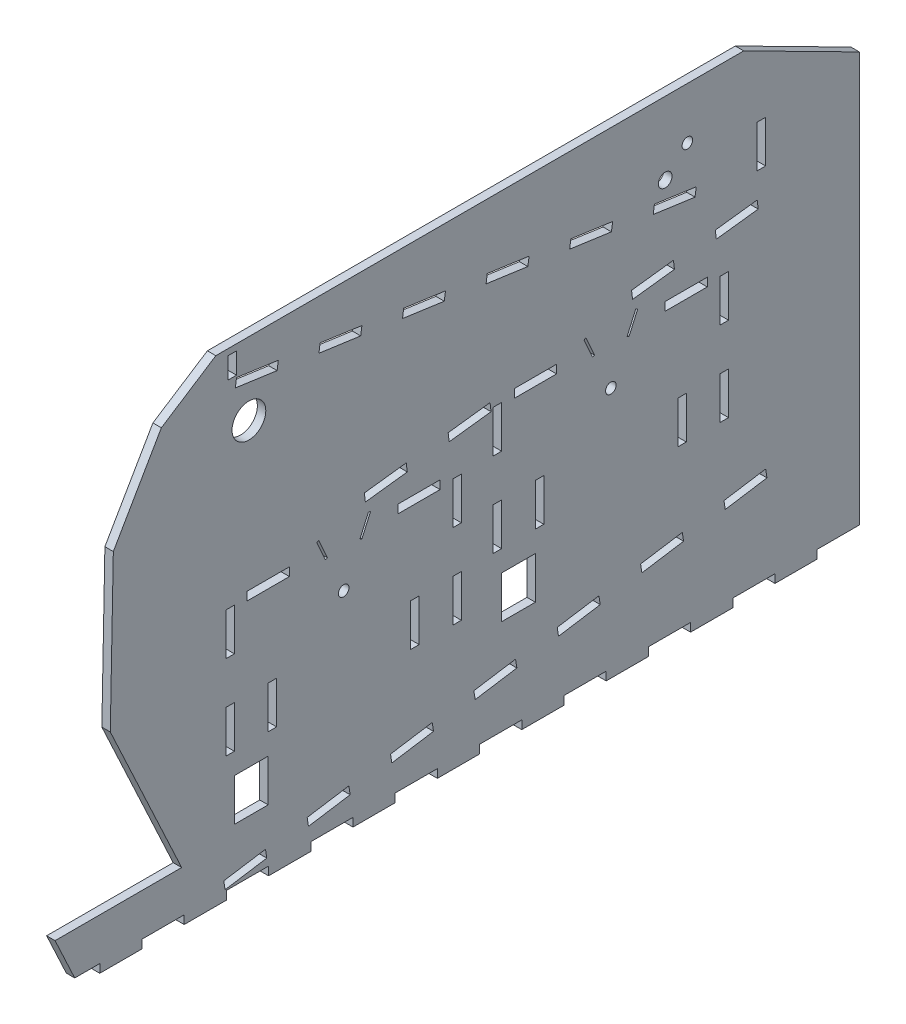
from build123d import *

# Parameters (mm, degrees)
SKETCH_1_W          = 16
SKETCH_1_H          = 20
SKETCH_1_W_2        = 4
SKETCH_1_R          = 2.5
SKETCH_1_W_3        = 20
SKETCH_1_H_2        = 4
SKETCH_1_H_3        = 10
SKETCH_1_R_2        = 3.25
EXTRUDE_12_DEPTH    = 4
SKETCH_4_R          = 8
CUT_EXTRUDE_4_DEPTH = 4


with BuildPart() as part:
    # Эскиз1 → Бобышка-Вытянуть12 (new body)
    with BuildSketch(Plane(origin=(0, 0, 0), x_dir=(0, 0, -1), z_dir=(1, 0, 0))):
        Polygon((-110.600725883, -2.680262939), (-76.770509831, -75.229395384), (-136.770509831, -75.229395384), (-127.444356668, -95.229395384), (-115.579126036, -95.229395384), (-115.579126036, -99.229395384), (-95.579126036, -99.229395384), (-95.579126036, -95.229395384), (-75.579126036, -95.229395384), (-75.579126036, -99.229395384), (-55.579126036, -99.229395384), (-55.579126036, -95.229395384), (-35.579126036, -95.229395384), (-35.579126036, -99.229395384), (-15.579126036, -99.229395384), (-15.579126036, -95.229395384), (4.420873964, -95.229395384), (4.420873964, -99.229395384), (24.420873964, -99.229395384), (24.420873964, -95.229395384), (44.420873964, -95.229395384), (44.420873964, -99.229395384), (64.420873964, -99.229395384), (64.420873964, -95.229395384), (84.420873964, -95.229395384), (84.420873964, -99.229395384), (104.420873964, -99.229395384), (104.420873964, -95.229395384), (124.420873964, -95.229395384), (124.420873964, -99.229395384), (144.420873964, -99.229395384), (144.420873964, -95.229395384), (164.420873964, -95.229395384), (164.420873964, -99.229395384), (184.420873964, -99.229395384), (184.420873964, -95.229395384), (204.420873964, -95.229395384), (204.420873964, -99.229395384), (224.420873964, -99.229395384), (224.420873964, -95.229395384), (244.420873964, -95.229395384), (244.420873964, 98.944706715), (189.622245063, 126.770604616), (-34.770509831, 126.770604616), (-60.579126036, 126.770604616), (-86.407669291, 110.078554792), (-109.160554377, 70.669401803), align=None)
        Polygon((-56.80504604, -90.676966538), (-37.046421413, -87.57910391), (-36.426848887, -91.530828835), (-56.185473514, -94.628691463), align=None, mode=Mode.SUBTRACT)
        with Locations((-43.770509831, -60)):
            Rectangle(SKETCH_1_W, SKETCH_1_H, mode=Mode.SUBTRACT)
        Polygon((-17.297512418, -84.419587937), (2.461112209, -81.321725309), (3.080684734, -85.273450234), (-16.677939892, -88.371312862), align=None, mode=Mode.SUBTRACT)
        Polygon((22.210021204, -78.162209336), (41.968645831, -75.064346707), (42.588218356, -79.016071633), (22.829593729, -82.113934261), align=None, mode=Mode.SUBTRACT)
        with Locations((-53.770509831, -30)):
            Rectangle(SKETCH_1_W_2, SKETCH_1_H, mode=Mode.SUBTRACT)
        with Locations((-53.770509831, 10)):
            Rectangle(SKETCH_1_W_2, SKETCH_1_H, mode=Mode.SUBTRACT)
        with Locations((-33.770509831, -30)):
            Rectangle(SKETCH_1_W_2, SKETCH_1_H, mode=Mode.SUBTRACT)
        with Locations((33.770509831, -30)):
            Rectangle(SKETCH_1_W_2, SKETCH_1_H, mode=Mode.SUBTRACT)
        with Locations((53.770509831, -30)):
            Rectangle(SKETCH_1_W_2, SKETCH_1_H, mode=Mode.SUBTRACT)
        Circle(SKETCH_1_R, mode=Mode.SUBTRACT)
        with Locations((53.770509831, 10)):
            Rectangle(SKETCH_1_W_2, SKETCH_1_H, mode=Mode.SUBTRACT)
        Polygon((61.717554826, -71.904830734), (81.476179452, -68.806968106), (82.095751978, -72.758693032), (62.337127351, -75.85655566), align=None, mode=Mode.SUBTRACT)
        Polygon((101.225088447, -65.647452133), (120.983713074, -62.549589505), (121.6032856, -66.50131443), (101.844660973, -69.599177058), align=None, mode=Mode.SUBTRACT)
        Polygon((140.732622069, -59.390073532), (160.491246696, -56.292210904), (161.110819221, -60.243935829), (141.352194595, -63.341798457), align=None, mode=Mode.SUBTRACT)
        Polygon((180.240155691, -53.13269493), (199.998780317, -50.034832302), (200.618352843, -53.986557228), (180.859728216, -57.084419856), align=None, mode=Mode.SUBTRACT)
        with Locations((82.85787393, -40.146526131)):
            Rectangle(SKETCH_1_W, SKETCH_1_H, mode=Mode.SUBTRACT)
        with Locations((72.85787393, -10.146526131)):
            Rectangle(SKETCH_1_W_2, SKETCH_1_H, mode=Mode.SUBTRACT)
        with Locations((92.85787393, -10.146526131)):
            Rectangle(SKETCH_1_W_2, SKETCH_1_H, mode=Mode.SUBTRACT)
        with Locations((160.398893592, -10.146526131)):
            Rectangle(SKETCH_1_W_2, SKETCH_1_H, mode=Mode.SUBTRACT)
        with Locations((180.398893592, -10.146526131)):
            Rectangle(SKETCH_1_W_2, SKETCH_1_H, mode=Mode.SUBTRACT)
        with Locations((-35.702882373, 20.674237137)):
            Rectangle(SKETCH_1_W_3, SKETCH_1_H_2, mode=Mode.SUBTRACT)
        Polygon((-8.641541676, 16.950627052), (-12.708908107, 26.086081629), (-11.795362649, 26.492818272), (-7.727996218, 17.357363695), align=None, mode=Mode.SUBTRACT)
        Polygon((12.708908107, 26.086081629), (8.641541676, 16.950627052), (7.727996218, 17.357363695), (11.795362649, 26.492818272), align=None, mode=Mode.SUBTRACT)
        with Locations((35.702882373, 20.674237137)):
            Rectangle(SKETCH_1_W_3, SKETCH_1_H_2, mode=Mode.SUBTRACT)
        Polygon((9.817627458, 35.215550401), (29.668550491, 37.652937269), (30.156027864, 33.682752663), (10.305104831, 31.245365794), align=None, mode=Mode.SUBTRACT)
        with Locations((-52.770509831, 118.862016811)):
            Rectangle(SKETCH_1_W_2, SKETCH_1_H_3, mode=Mode.SUBTRACT)
        Polygon((27.894243264, 97.767096459), (28.450935668, 101.728168734), (48.256297043, 98.944706715), (47.699604639, 94.98363444), align=None, mode=Mode.SUBTRACT)
        Polygon((-51.327202235, 108.900944536), (-50.770509831, 112.862016811), (-30.965148456, 110.078554792), (-31.52184086, 106.117482517), align=None, mode=Mode.SUBTRACT)
        Polygon((-11.716479485, 103.334020497), (-11.159787082, 107.295092772), (8.645574293, 104.511630753), (8.088881889, 100.550558478), align=None, mode=Mode.SUBTRACT)
        with Locations((72.85787393, 29.853473869)):
            Rectangle(SKETCH_1_W_2, SKETCH_1_H, mode=Mode.SUBTRACT)
        Polygon((49.519473523, 40.090324137), (69.370396556, 42.527711005), (69.85787393, 38.557526399), (50.006950897, 36.120139531), align=None, mode=Mode.SUBTRACT)
        with Locations((90.925501388, 40.527711005)):
            Rectangle(SKETCH_1_W_3, SKETCH_1_H_2, mode=Mode.SUBTRACT)
        with Locations((126.628383761, 19.853473869)):
            Circle(SKETCH_1_R, mode=Mode.SUBTRACT)
        Polygon((113.919475654, 45.939555497), (114.833021112, 46.34629214), (118.900387543, 37.210837564), (117.986842085, 36.804100921), align=None, mode=Mode.SUBTRACT)
        Polygon((135.269925437, 36.804100921), (134.35637998, 37.210837564), (138.42374641, 46.34629214), (139.337291868, 45.939555497), align=None, mode=Mode.SUBTRACT)
        Polygon((136.446011219, 55.06902427), (156.296934252, 57.506411138), (156.784411625, 53.536226531), (136.933488593, 51.098839663), align=None, mode=Mode.SUBTRACT)
        with Locations((162.331266135, 40.527711005)):
            Rectangle(SKETCH_1_W_3, SKETCH_1_H_2, mode=Mode.SUBTRACT)
        with Locations((180.398893592, 29.853473869)):
            Rectangle(SKETCH_1_W_2, SKETCH_1_H, mode=Mode.SUBTRACT)
        Polygon((176.147857285, 59.943798006), (195.998780317, 62.381184874), (196.486257691, 58.411000267), (176.635334658, 55.973613399), align=None, mode=Mode.SUBTRACT)
        Polygon((67.504966014, 92.200172421), (68.061658418, 96.161244696), (87.867019793, 93.377782676), (87.310327389, 89.416710401), align=None, mode=Mode.SUBTRACT)
        Polygon((107.115688764, 86.633248382), (107.672381167, 90.594320657), (127.477742542, 87.810858638), (126.921050138, 83.849786363), align=None, mode=Mode.SUBTRACT)
        Polygon((146.726411513, 81.066324344), (147.283103917, 85.027396619), (167.088465292, 82.2439346), (166.531772888, 78.282862325), align=None, mode=Mode.SUBTRACT)
        with Locations((152.394391132, 92.387672627)):
            Circle(SKETCH_1_R_2, mode=Mode.SUBTRACT)
        with Locations((197.998780317, 84.338095955)):
            Rectangle(SKETCH_1_W_2, SKETCH_1_H, mode=Mode.SUBTRACT)
        with Locations((162.881367645, 102.338718984)):
            Circle(SKETCH_1_R, mode=Mode.SUBTRACT)
    extrude(amount=EXTRUDE_12_DEPTH)

    # Эскиз4 → Вырез-Вытянуть4 (cut)
    with BuildSketch(Plane(origin=(4, 0, 0), x_dir=(0, 0, -1), z_dir=(1, 0, 0))):
        with Locations((-44.900850993, 92.32385212)):
            Circle(SKETCH_4_R)
    extrude(amount=-CUT_EXTRUDE_4_DEPTH, mode=Mode.SUBTRACT)


solid = part.part
